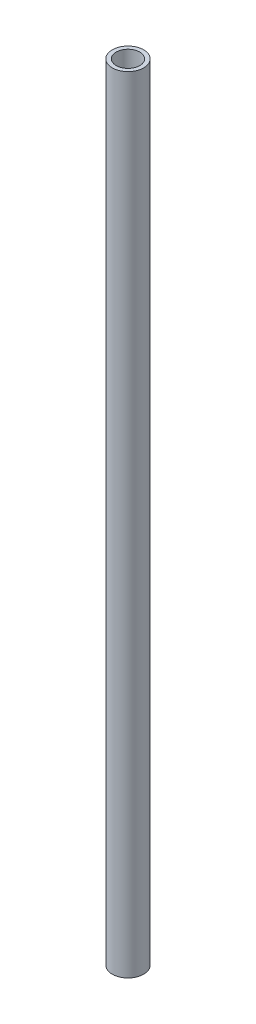
from build123d import *

# Parameters (mm, degrees)
SKETCH1_R      = 20
SKETCH1_R_2    = 15
EXTRUDE1_DEPTH = 1000


with BuildPart() as part:
    # Sketch1 → Extrude1 (new body)
    with BuildSketch(Plane(origin=(0, 0, 0), x_dir=(1, 0, 0), z_dir=(0, 1, 0))):
        with Locations(Location((0, 0, 0), (0, 0, 270))):  # turned: the seam where the file's is
            Circle(SKETCH1_R)
        with Locations(Location((0, 0, 0), (0, 0, 270))):  # turned: the seam where the file's is
            Circle(SKETCH1_R_2, mode=Mode.SUBTRACT)
    extrude(amount=EXTRUDE1_DEPTH)


solid = part.part
